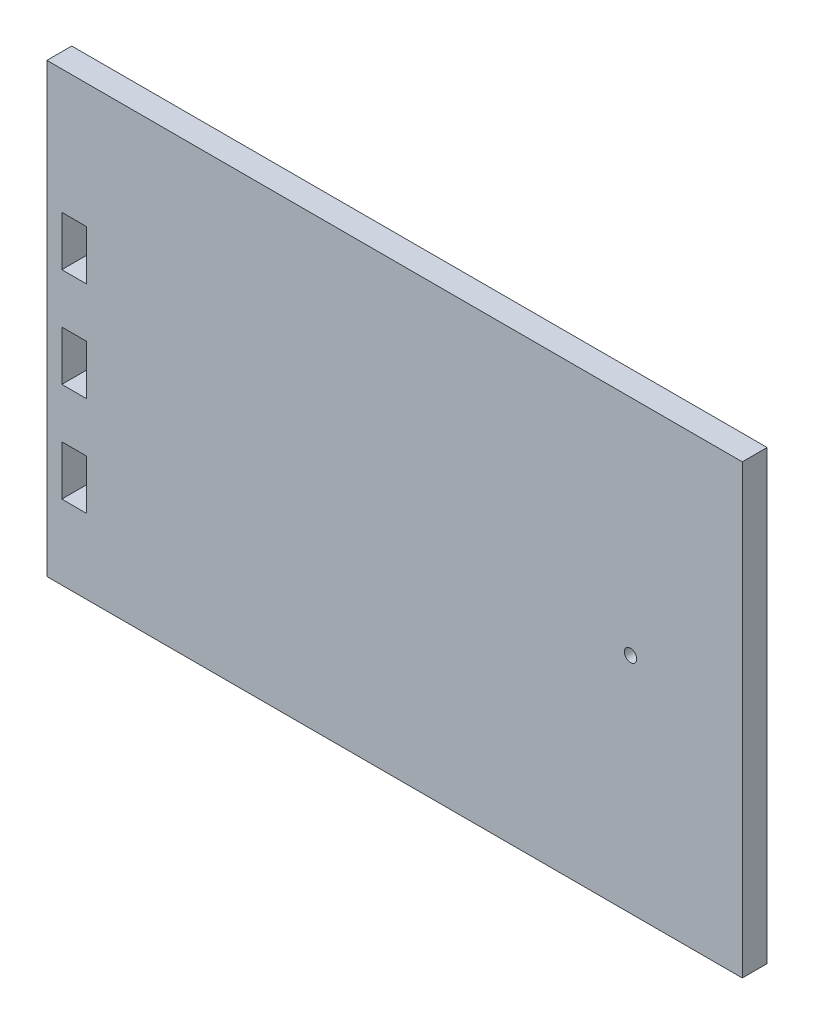
from build123d import *

# Parameters (mm, degrees)
SKETCH2_W           = 355.6
SKETCH2_H           = 228.6
BOSS_EXTRUDE1_DEPTH = 12.7
SKETCH3_R           = 3.175
CUT_EXTRUDE1_DEPTH  = 12.7
SKETCH4_W           = 12.7
SKETCH4_H           = 25.4
CUT_EXTRUDE2_DEPTH  = 13.7


with BuildPart() as part:
    # Sketch2 → Boss-Extrude1 (new body)
    with BuildSketch(Plane.XY):
        with Locations((177.8, -114.3)):
            Rectangle(SKETCH2_W, SKETCH2_H)
    extrude(amount=BOSS_EXTRUDE1_DEPTH)

    # Sketch3 → Cut-Extrude1 (cut)
    with BuildSketch(Plane.XY.offset(12.7)):
        with Locations((298.45, -114.3)):
            Circle(SKETCH3_R)
    extrude(amount=-CUT_EXTRUDE1_DEPTH, mode=Mode.SUBTRACT)

    # Sketch4 → Cut-Extrude2 (cut, through all)
    with BuildSketch(Plane.XY.offset(12.7)):
        with Locations((13.97, -76.2)):
            Rectangle(SKETCH4_W, SKETCH4_H)
        with Locations((13.97, -127)):
            Rectangle(SKETCH4_W, SKETCH4_H)
        with Locations((13.97, -177.8)):
            Rectangle(SKETCH4_W, SKETCH4_H)
    extrude(amount=-CUT_EXTRUDE2_DEPTH, mode=Mode.SUBTRACT)


solid = part.part
